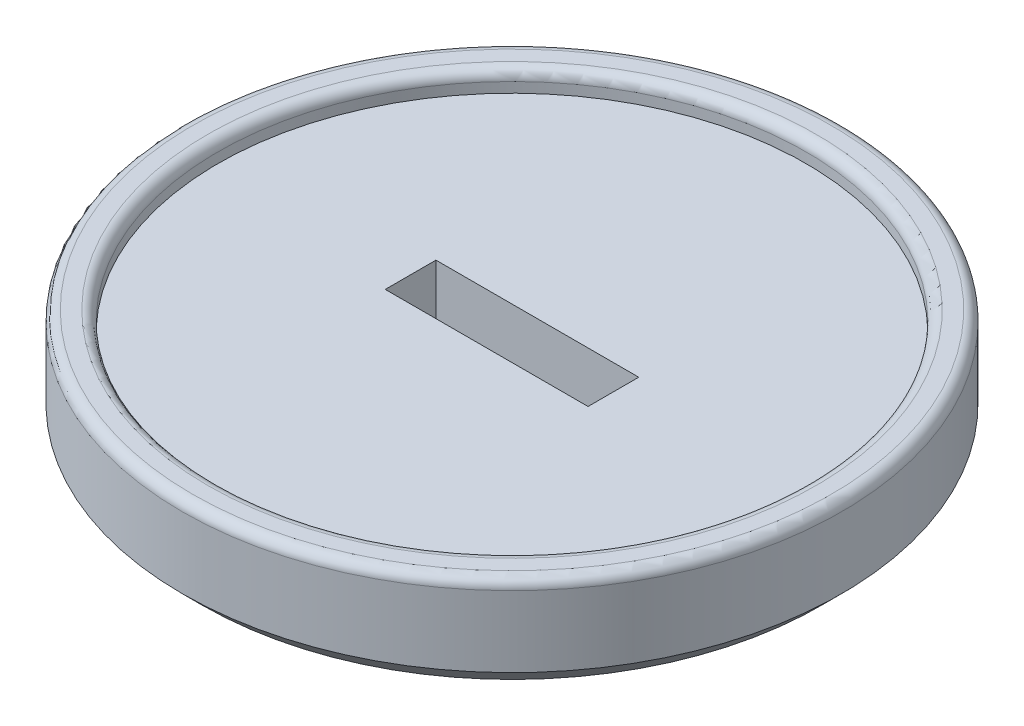
from build123d import *

# Parameters (mm, degrees)
SKETCH1_R           = 32.5
BOSS_EXTRUDE4_DEPTH = 10
CUT_EXTRUDE1_REACH  = 12
SKETCH4_W           = 20
SKETCH4_H           = 5
SKETCH5_R           = 29
CUT_EXTRUDE3_DEPTH  = 2
FILLET1_R           = 1
FILLET2_R           = 1
CHAMFER1_SIZE       = 2


with BuildPart() as part:
    # Sketch1 → Boss-Extrude4 (new body)
    with BuildSketch(Plane(origin=(0, 0, 0), x_dir=(1, 0, 0), z_dir=(0, 1, 0))):
        with Locations(Location((0, 0, 0), (0, 0, 270))):  # turned: the seam where the file's is
            Circle(SKETCH1_R)
    extrude(amount=BOSS_EXTRUDE4_DEPTH)

    # Sketch4 → Cut-Extrude1 (cut, up to next)
    with BuildSketch(Plane(origin=(0, 10, 0), x_dir=(1, 0, 0), z_dir=(0, 1, 0)), mode=Mode.PRIVATE) as cut_extrude1_sk1:
        Rectangle(SKETCH4_W, SKETCH4_H)
    cut_extrude1_tool1 = extrude(cut_extrude1_sk1.sketch, amount=-CUT_EXTRUDE1_REACH, mode=Mode.PRIVATE) & part.part
    add(cut_extrude1_tool1.solids().sort_by_distance((0, 10, 0))[0], mode=Mode.SUBTRACT)

    # Sketch5 → Cut-Extrude3 (cut)
    with BuildSketch(Plane(origin=(0, 10, 0), x_dir=(1, 0, 0), z_dir=(0, 1, 0))):
        with Locations(Location((0, 0, 0), (0, 0, 270))):  # turned: the seam where the file's is
            Circle(SKETCH5_R)
    extrude(amount=-CUT_EXTRUDE3_DEPTH, mode=Mode.SUBTRACT)

    # Fillet1
    fillet1_edges = [part.edges().sort_by_distance(p)[0] for p in [
        (0, 10, -32.5),
    ]]
    fillet(fillet1_edges, radius=FILLET1_R)

    # Fillet2
    fillet2_edges = [part.edges().sort_by_distance(p)[0] for p in [
        (0, 10, -29),
    ]]
    fillet(fillet2_edges, radius=FILLET2_R)

    # Chamfer1
    chamfer1_edges = [part.edges().sort_by_distance(p)[0] for p in [
        (0, 0, -32.5),
    ]]
    chamfer(chamfer1_edges, length=CHAMFER1_SIZE)


solid = part.part
